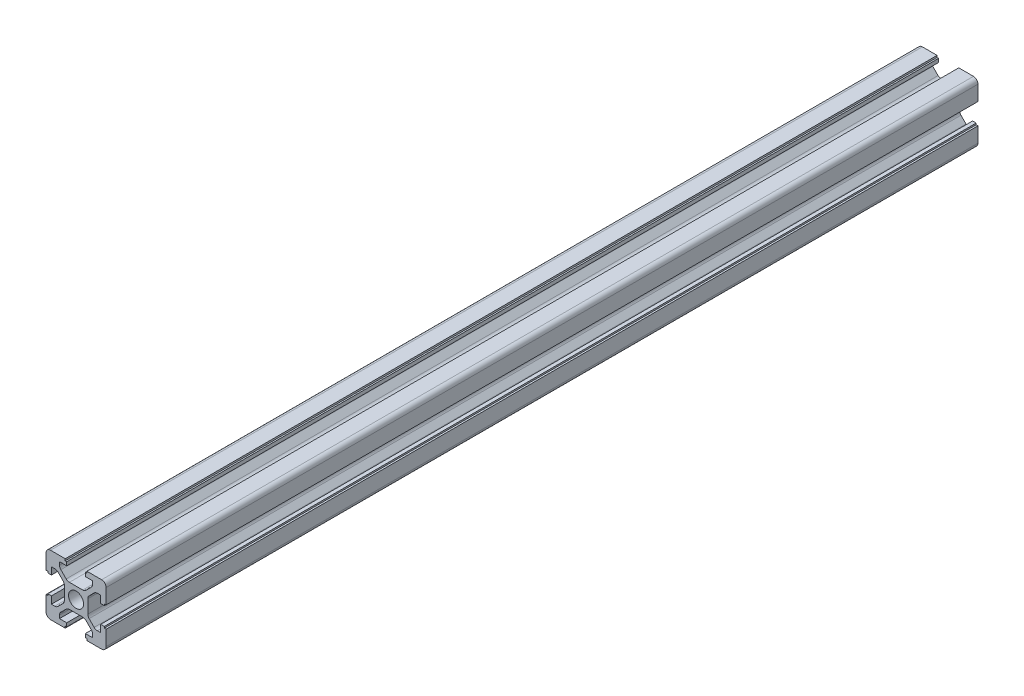
from build123d import *

# Parameters (mm, degrees)
SKETCH1_R           = 2.5
BOSS_EXTRUDE1_DEPTH = 290


with BuildPart() as part:
    # Sketch1 → Boss-Extrude1 (new body)
    with BuildSketch(Plane.XY):
        with BuildLine():
            Line((-3.6, -10), (-8.5, -10))
            ThreePointArc((-8.5, -10), (-9.560660172, -9.560660172), (-10, -8.5))
            Line((-10, -8.5), (-10, -3.5))
            Line((-10, -3.5), (-9.4, -3.5))
            Line((-9.4, -3.5), (-9.4, -3))
            Line((-9.4, -3), (-8.2, -3))
            Line((-8.2, -3), (-8.2, -5.4))
            Line((-8.2, -5.4), (-7.081980515, -5.4))
            ThreePointArc((-7.081980515, -5.4), (-6.507955367, -5.285819299), (-6.021320344, -4.960660172))
            Line((-6.021320344, -4.960660172), (-4.339339828, -3.278679656))
            ThreePointArc((-4.339339828, -3.278679656), (-4.014180701, -2.792044633), (-3.9, -2.218019485))
            Line((-3.9, -2.218019485), (-3.9, 2.218019485))
            ThreePointArc((-3.9, 2.218019485), (-4.014180701, 2.792044633), (-4.339339828, 3.278679656))
            Line((-4.339339828, 3.278679656), (-6.021320344, 4.960660172))
            ThreePointArc((-6.021320344, 4.960660172), (-6.507955367, 5.285819299), (-7.081980515, 5.4))
            Line((-7.081980515, 5.4), (-8.2, 5.4))
            Line((-8.2, 5.4), (-8.2, 3))
            Line((-8.2, 3), (-9.4, 3))
            Line((-9.4, 3), (-9.4, 3.5))
            Line((-9.4, 3.5), (-10, 3.5))
            Line((-10, 3.5), (-10, 8.5))
            ThreePointArc((-10, 8.5), (-9.560660172, 9.560660172), (-8.5, 10))
            Line((-8.5, 10), (-3.6, 10))
            Line((-3.6, 10), (-3.6, 9.4))
            Line((-3.6, 9.4), (-3.1, 9.4))
            Line((-3.1, 9.4), (-3.1, 8.2))
            Line((-3.1, 8.2), (-5.5, 8.2))
            Line((-5.5, 8.2), (-5.5, 7.181980515))
            ThreePointArc((-5.5, 7.181980515), (-5.385819299, 6.607955367), (-5.060660172, 6.121320344))
            Line((-5.060660172, 6.121320344), (-3.278679656, 4.339339828))
            ThreePointArc((-3.278679656, 4.339339828), (-2.792044633, 4.014180701), (-2.218019485, 3.9))
            Line((-2.218019485, 3.9), (2.218019485, 3.9))
            ThreePointArc((2.218019485, 3.9), (2.792044633, 4.014180701), (3.278679656, 4.339339828))
            Line((3.278679656, 4.339339828), (5.060660172, 6.121320344))
            ThreePointArc((5.060660172, 6.121320344), (5.385819299, 6.607955367), (5.5, 7.181980515))
            Line((5.5, 7.181980515), (5.5, 8.2))
            Line((5.5, 8.2), (3.1, 8.2))
            Line((3.1, 8.2), (3.1, 9.4))
            Line((3.1, 9.4), (3.6, 9.4))
            Line((3.6, 9.4), (3.6, 10))
            Line((3.6, 10), (8.5, 10))
            ThreePointArc((8.5, 10), (9.560660172, 9.560660172), (10, 8.5))
            Line((10, 8.5), (10, 3.5))
            Line((10, 3.5), (9.4, 3.5))
            Line((9.4, 3.5), (9.4, 3))
            Line((9.4, 3), (8.2, 3))
            Line((8.2, 3), (8.2, 5.4))
            Line((8.2, 5.4), (7.081980515, 5.4))
            ThreePointArc((7.081980515, 5.4), (6.507955367, 5.285819299), (6.021320344, 4.960660172))
            Line((6.021320344, 4.960660172), (4.339339828, 3.278679656))
            ThreePointArc((4.339339828, 3.278679656), (4.014180701, 2.792044633), (3.9, 2.218019485))
            Line((3.9, 2.218019485), (3.9, -2.218019485))
            ThreePointArc((3.9, -2.218019485), (4.014180701, -2.792044633), (4.339339828, -3.278679656))
            Line((4.339339828, -3.278679656), (6.021320344, -4.960660172))
            ThreePointArc((6.021320344, -4.960660172), (6.507955367, -5.285819299), (7.081980515, -5.4))
            Line((7.081980515, -5.4), (8.2, -5.4))
            Line((8.2, -5.4), (8.2, -3))
            Line((8.2, -3), (9.4, -3))
            Line((9.4, -3), (9.4, -3.5))
            Line((9.4, -3.5), (10, -3.5))
            Line((10, -3.5), (10, -8.5))
            ThreePointArc((10, -8.5), (9.560660172, -9.560660172), (8.5, -10))
            Line((8.5, -10), (3.6, -10))
            Line((3.6, -10), (3.6, -9.4))
            Line((3.6, -9.4), (3.1, -9.4))
            Line((3.1, -9.4), (3.1, -8.2))
            Line((3.1, -8.2), (5.5, -8.2))
            Line((5.5, -8.2), (5.5, -7.181980515))
            ThreePointArc((5.5, -7.181980515), (5.385819299, -6.607955367), (5.060660172, -6.121320344))
            Line((5.060660172, -6.121320344), (3.278679656, -4.339339828))
            ThreePointArc((3.278679656, -4.339339828), (2.792044633, -4.014180701), (2.218019485, -3.9))
            Line((2.218019485, -3.9), (-2.218019485, -3.9))
            ThreePointArc((-2.218019485, -3.9), (-2.792044633, -4.014180701), (-3.278679656, -4.339339828))
            Line((-3.278679656, -4.339339828), (-5.060660172, -6.121320344))
            ThreePointArc((-5.060660172, -6.121320344), (-5.385819299, -6.607955367), (-5.5, -7.181980515))
            Line((-5.5, -7.181980515), (-5.5, -8.2))
            Line((-5.5, -8.2), (-3.1, -8.2))
            Line((-3.1, -8.2), (-3.1, -9.4))
            Line((-3.1, -9.4), (-3.6, -9.4))
            Line((-3.6, -9.4), (-3.6, -10))
        make_face()
        Circle(SKETCH1_R, mode=Mode.SUBTRACT)
    extrude(amount=BOSS_EXTRUDE1_DEPTH)


solid = part.part
